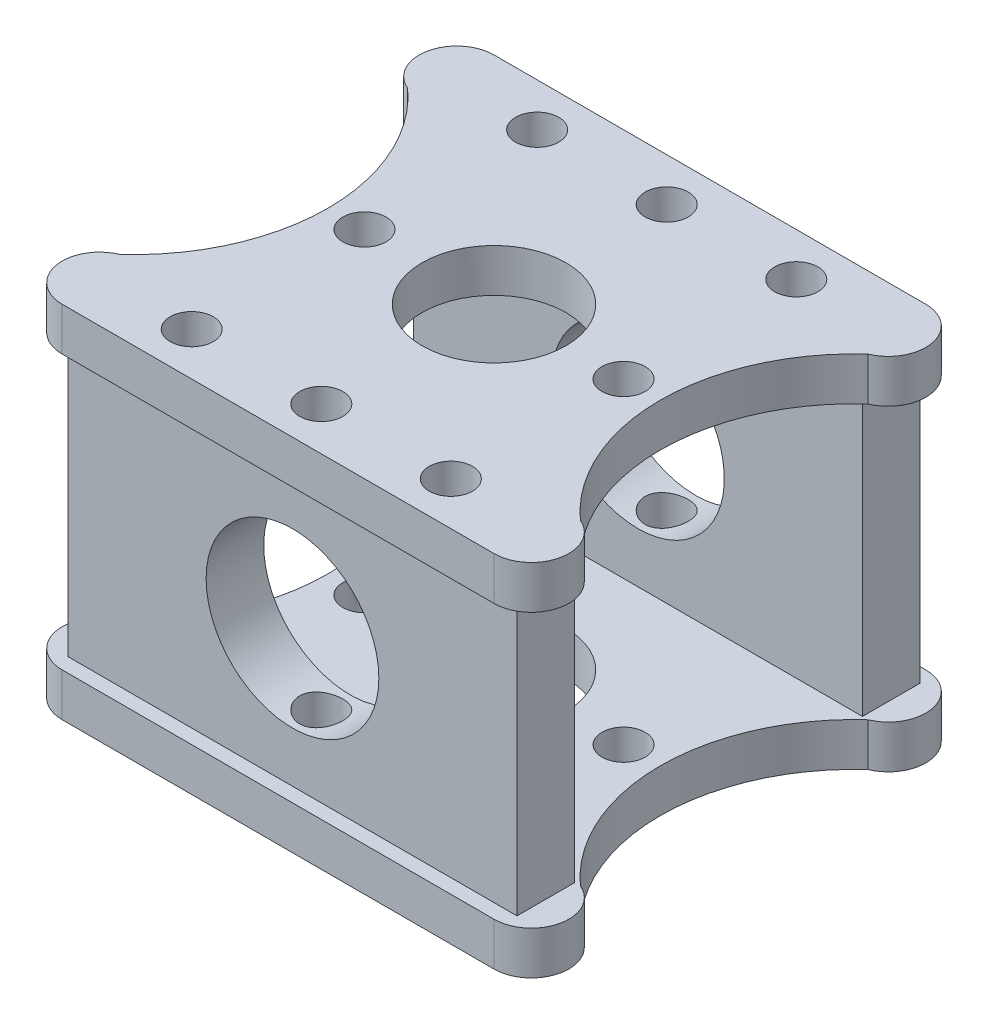
from build123d import *

# Parameters (mm, degrees)
ESQUISSE1_R                  = 5
ESQUISSE1_R_2                = 1.5
BOSS_EXTRU_1_DEPTH           = 25
ENL_V_MAT_EXTRU_1_DEPTH      = 25
ENL_V_MAT_EXTRU_1_DEPTH_BACK = 25
ESQUISSE2_W                  = 20
ESQUISSE2_H                  = 19
ESQUISSE2_W_2                = 4.56072091
ESQUISSE2_W_3                = 3.825642854
ESQUISSE3_R                  = 6
ESQUISSE3_W                  = 8.37073205
ESQUISSE3_H                  = 19
ESQUISSE3_W_2                = 9.375022173
ENL_V_MAT_EXTRU_2_DEPTH      = 30


with BuildPart() as part:
    # Esquisse1 → Boss.-Extru.1 (new body)
    with BuildSketch(Plane(origin=(0, 0, 0), x_dir=(1, 0, 0), z_dir=(0, 1, 0))):
        with BuildLine():
            Line((-15, 15), (15, 15))
            ThreePointArc((15, 15), (17.549509757, 12.909901951), (16, 10))
            ThreePointArc((16, 10), (11.546375953, 0), (16, -10))
            ThreePointArc((16, -10), (17.549509757, -12.909901951), (15, -15))
            Line((15, -15), (-15, -15))
            ThreePointArc((-15, -15), (-17.549509757, -12.909901951), (-16, -10))
            ThreePointArc((-16, -10), (-11.546375953, 0), (-16, 10))
            ThreePointArc((-16, 10), (-17.549509757, 12.909901951), (-15, 15))
        make_face()
        Circle(ESQUISSE1_R, mode=Mode.SUBTRACT)
        with Locations((9, 0)):
            Circle(ESQUISSE1_R_2, mode=Mode.SUBTRACT)
        with Locations((-9, 0)):
            Circle(ESQUISSE1_R_2, mode=Mode.SUBTRACT)
        with Locations((-9, 12)):
            Circle(ESQUISSE1_R_2, mode=Mode.SUBTRACT)
        with Locations((9, 12)):
            Circle(ESQUISSE1_R_2, mode=Mode.SUBTRACT)
        with Locations((-9, -12)):
            Circle(ESQUISSE1_R_2, mode=Mode.SUBTRACT)
        with Locations((9, -12)):
            Circle(ESQUISSE1_R_2, mode=Mode.SUBTRACT)
        with Locations((0, -12)):
            Circle(ESQUISSE1_R_2, mode=Mode.SUBTRACT)
        with Locations((0, 12)):
            Circle(ESQUISSE1_R_2, mode=Mode.SUBTRACT)
    extrude(amount=BOSS_EXTRU_1_DEPTH)

    # Esquisse2 → Enlèv. mat.-Extru.1 (cut, two sides: drawn at the far end of the back side and taken through both)
    with BuildSketch(Plane(origin=(0, 0, 0), x_dir=(0, 0, -1), z_dir=(1, 0, 0)).offset(-ENL_V_MAT_EXTRU_1_DEPTH_BACK)):
        with Locations((0, 12.5)):
            Rectangle(ESQUISSE2_W, ESQUISSE2_H)
        with Locations((16.280360455, 12.5)):
            Rectangle(ESQUISSE2_W_2, ESQUISSE2_H)
        with Locations((-15.912821427, 12.5)):
            Rectangle(ESQUISSE2_W_3, ESQUISSE2_H)
    extrude(amount=ENL_V_MAT_EXTRU_1_DEPTH + ENL_V_MAT_EXTRU_1_DEPTH_BACK, mode=Mode.SUBTRACT)

    # Esquisse3 → Enlèv. mat.-Extru.2 (cut)
    with BuildSketch(Plane.XY.offset(14)):
        with Locations((0, 12.5)):
            Circle(ESQUISSE3_R)
        with Locations((-19.785366025, 12.5)):
            Rectangle(ESQUISSE3_W, ESQUISSE3_H)
        with Locations((20.287511087, 12.5)):
            Rectangle(ESQUISSE3_W_2, ESQUISSE3_H)
    extrude(amount=-ENL_V_MAT_EXTRU_2_DEPTH, mode=Mode.SUBTRACT)


solid = part.part
